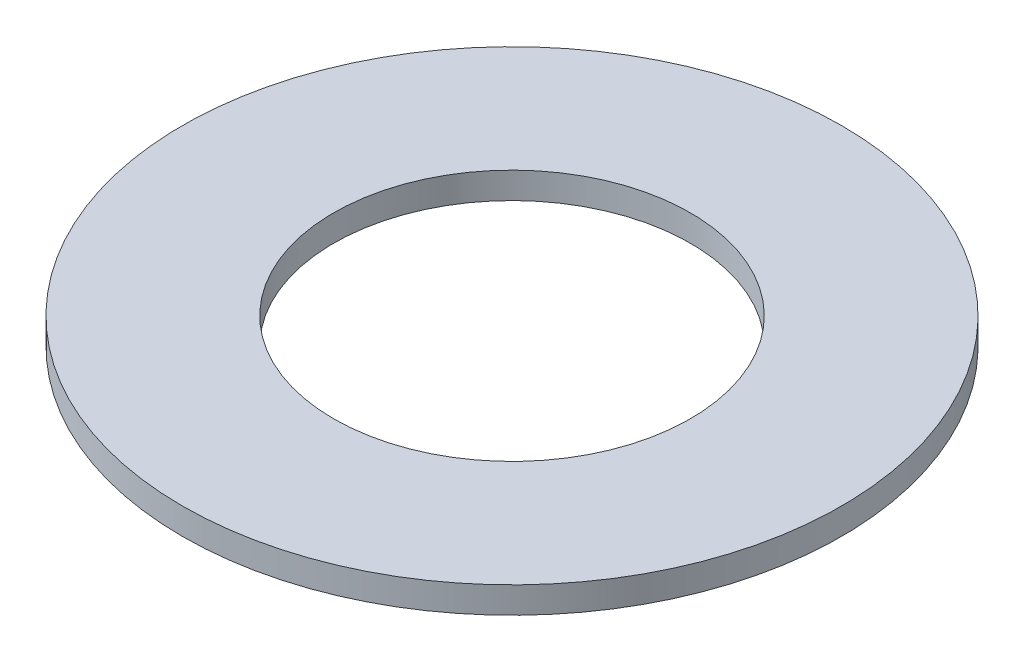
from build123d import *

# Parameters (mm, degrees)
SKETCH1_R           = 19.05
BOSS_EXTRUDE1_DEPTH = 1.524
SKETCH5_R           = 10.3124
CUT_EXTRUDE1_DEPTH  = 2.524


with BuildPart() as part:
    # Sketch1 → Boss-Extrude1 (new body)
    with BuildSketch(Plane(origin=(0, 0, 0), x_dir=(1, 0, 0), z_dir=(0, 1, 0))):
        Circle(SKETCH1_R)
    extrude(amount=BOSS_EXTRUDE1_DEPTH)

    # Sketch5 → Cut-Extrude1 (cut, through all)
    with BuildSketch(Plane(origin=(0, 1.524, 0), x_dir=(-1, 0, 0), z_dir=(0, 1, 0))):
        Circle(SKETCH5_R)
    extrude(amount=-CUT_EXTRUDE1_DEPTH, mode=Mode.SUBTRACT)


solid = part.part
